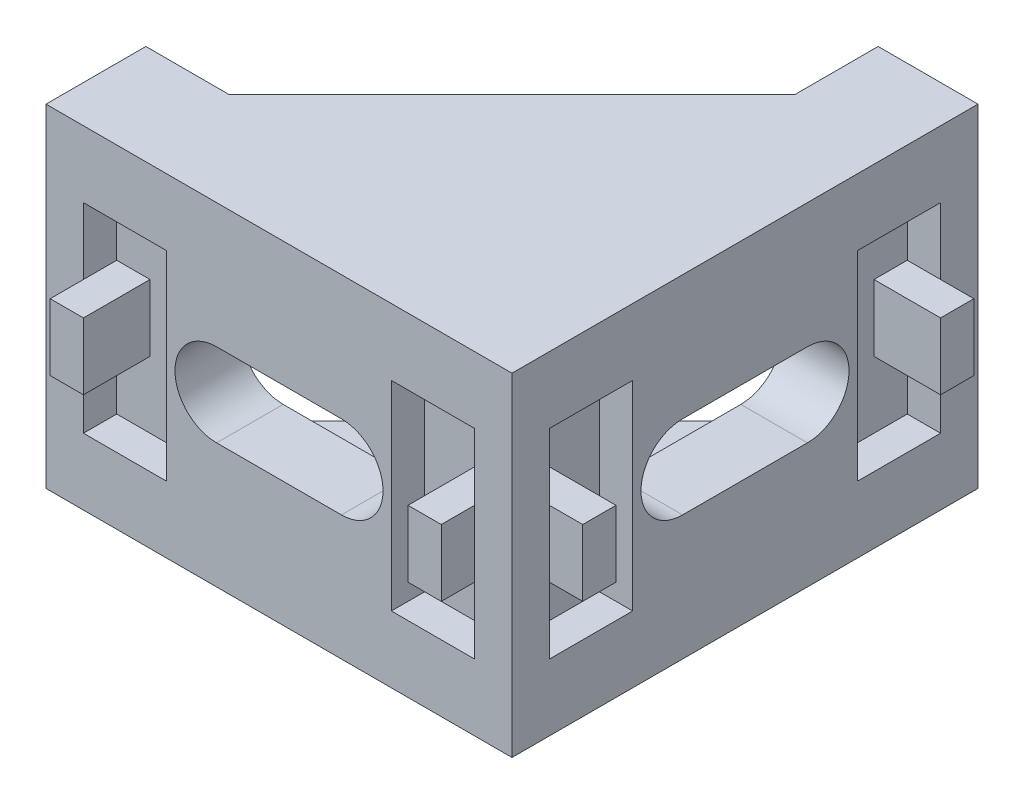
from build123d import *

# Parameters (mm, degrees)
BOSS_EXTRUDE1_DEPTH = 20
SKETCH2_W           = 24
SKETCH2_H           = 14
CUT_EXTRUDE1_DEPTH  = 24
SKETCH3_W           = 5
SKETCH3_H           = 12
CUT_EXTRUDE2_DEPTH  = 2
SKETCH4_W           = 2
SKETCH4_H           = 4
BOSS_EXTRUDE2_DEPTH = 4
CUT_EXTRUDE3_DEPTH  = 4


with BuildPart() as part:
    # Sketch1 → Boss-Extrude1 (new body)
    with BuildSketch(Plane(origin=(0, 0, 0), x_dir=(1, 0, 0), z_dir=(0, 1, 0))):
        Polygon((-28, 0), (0, 0), (0, 28), (-6, 28), (-6, 23), (-23, 6), (-28, 6), align=None)
    extrude(amount=BOSS_EXTRUDE1_DEPTH)

    # Sketch2 → Cut-Extrude1 (cut)
    with BuildSketch(Plane(origin=(0, 0, -28), x_dir=(-1, 0, 0), z_dir=(0, 0, -1))):
        with Locations((16, 10)):
            Rectangle(SKETCH2_W, SKETCH2_H)
    extrude(amount=-CUT_EXTRUDE1_DEPTH, mode=Mode.SUBTRACT)

    # Sketch3 → Cut-Extrude2 (cut)
    with BuildSketch(Plane.XY):
        with Locations((-23.25, 10)):
            Rectangle(SKETCH3_W, SKETCH3_H)
        with Locations((-4.75, 10)):
            Rectangle(SKETCH3_W, SKETCH3_H)
    cut_extrude2 = extrude(amount=-CUT_EXTRUDE2_DEPTH, mode=Mode.SUBTRACT)

    # Sketch4 → Boss-Extrude2 (add)
    with BuildSketch(Plane.XY.offset(-2)):
        with Locations((-24.75, 10)):
            Rectangle(SKETCH4_W, SKETCH4_H)
        with Locations((-3.25, 10)):
            Rectangle(SKETCH4_W, SKETCH4_H)
    boss_extrude2 = extrude(amount=BOSS_EXTRUDE2_DEPTH)

    # Mirror11: Cut-Extrude2, Boss-Extrude2 across plane
    add(cut_extrude2.mirror(Plane(origin=(0, 0, 0), x_dir=(0.707106781, 0, 0.707106781), z_dir=(-0.707106781, 0, 0.707106781))), mode=Mode.SUBTRACT)
    add(boss_extrude2.mirror(Plane(origin=(0, 0, 0), x_dir=(0.707106781, 0, 0.707106781), z_dir=(-0.707106781, 0, 0.707106781))))

    # Sketch5 → Cut-Extrude3 (cut)
    with BuildSketch(Plane(origin=(0, 0, -4), x_dir=(-1, 0, 0), z_dir=(0, 0, -1))):
        with BuildLine():
            Line((10.25, 12.5), (17.75, 12.5))
            ThreePointArc((17.75, 12.5), (20.25, 10), (17.75, 7.5))
            Line((17.75, 7.5), (10.25, 7.5))
            ThreePointArc((10.25, 7.5), (7.75, 10), (10.25, 12.5))
        make_face()
    cut_extrude3 = extrude(amount=-CUT_EXTRUDE3_DEPTH, mode=Mode.SUBTRACT)

    # Mirror12: Cut-Extrude3 across plane
    add(cut_extrude3.mirror(Plane(origin=(0, 0, 0), x_dir=(0.707106781, 0, 0.707106781), z_dir=(-0.707106781, 0, 0.707106781))), mode=Mode.SUBTRACT)


solid = part.part
